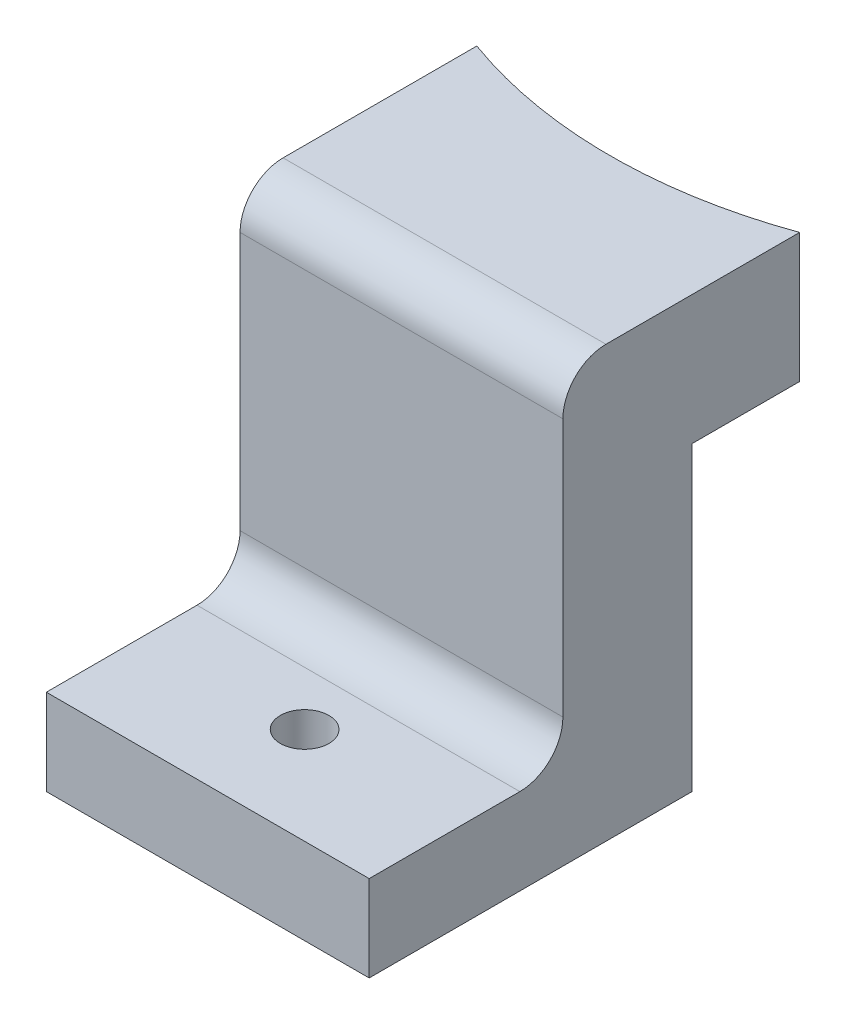
from build123d import *

# Parameters (mm, degrees)
SKETCH1_W                 = 15
SKETCH1_H                 = 10
BOSS_EXTRUDE1_DEPTH       = 6
SKETCH2_R                 = 22
CUT_EXTRUDE1_DEPTH        = 9
SKETCH3_W                 = 15
SKETCH3_H                 = 6
BOSS_EXTRUDE2_DEPTH       = 20
SKETCH4_W                 = 15
SKETCH4_H                 = 4
BOSS_EXTRUDE3_DEPTH       = 9
F_4_40_TAPPED_HOLE2_D     = 2.2606
F_4_40_TAPPED_HOLE2_DEPTH = 7.6
F_4_40_TAPPED_HOLE2_TIP   = 0.679152758
FILLET2_R                 = 2


with BuildPart() as part:
    # Sketch1 → Boss-Extrude1 (new body)
    with BuildSketch(Plane(origin=(0, 0, 0), x_dir=(1, 0, 0), z_dir=(0, 1, 0))):
        Rectangle(SKETCH1_W, SKETCH1_H)
    extrude(amount=BOSS_EXTRUDE1_DEPTH)

    # Sketch2 → Cut-Extrude1 (cut)
    with BuildSketch(Plane(origin=(0, 6, 0), x_dir=(1, 0, 0), z_dir=(0, 1, 0))):
        with Locations((0, 25.68211788)):
            Circle(SKETCH2_R)
    extrude(amount=-CUT_EXTRUDE1_DEPTH, mode=Mode.SUBTRACT)

    # Sketch3 → Boss-Extrude2 (add)
    with BuildSketch(Plane(origin=(0, 6, 0), x_dir=(1, 0, 0), z_dir=(0, 1, 0))):
        with Locations((0, -3)):
            Rectangle(SKETCH3_W, SKETCH3_H)
    extrude(amount=-BOSS_EXTRUDE2_DEPTH)

    # Sketch4 → Boss-Extrude3 (add)
    with BuildSketch(Plane.XY.offset(6)):
        with Locations((0, -12)):
            Rectangle(SKETCH4_W, SKETCH4_H)
    extrude(amount=BOSS_EXTRUDE3_DEPTH)

    # #4-40 Tapped Hole2
    with Locations(Plane(origin=(0, -14, 0), x_dir=(-1, 0, 0), z_dir=(0, -1, 0))):
        with Locations((0, -10.5)):
            Hole(F_4_40_TAPPED_HOLE2_D / 2, depth=F_4_40_TAPPED_HOLE2_DEPTH)
            with Locations((0, 0, -(F_4_40_TAPPED_HOLE2_DEPTH + F_4_40_TAPPED_HOLE2_TIP / 2))):  # 118° drill point
                Cone(0, F_4_40_TAPPED_HOLE2_D / 2, F_4_40_TAPPED_HOLE2_TIP, mode=Mode.SUBTRACT)

    # Fillet2
    fillet2_edges = [part.edges().sort_by_distance(p)[0] for p in [
        (0, 6, 6),
        (0, -10, 6),
    ]]
    fillet(fillet2_edges, radius=FILLET2_R)


solid = part.part
